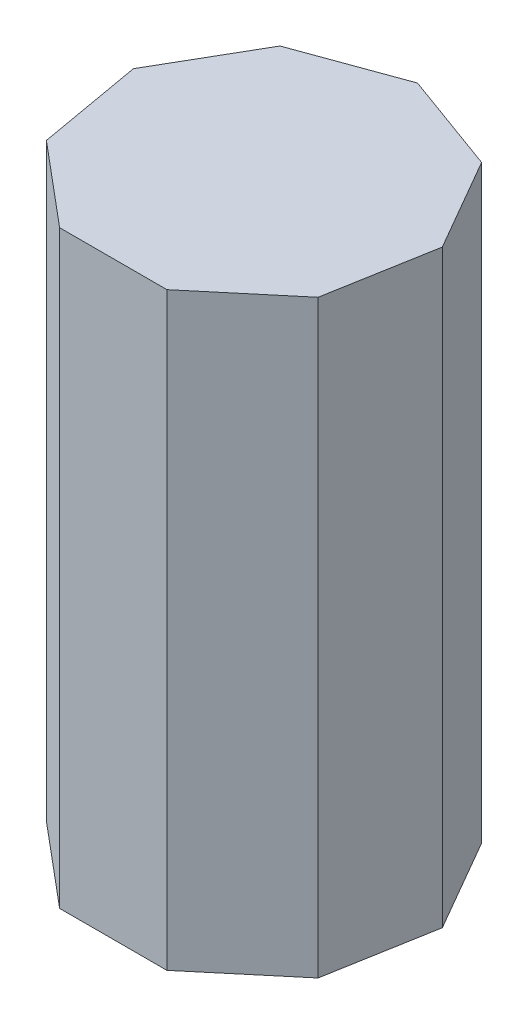
from build123d import *

# Parameters (mm, degrees)
EXTRUDE1_DEPTH = 20


with BuildPart() as part:
    # Sketch1 → Extrude1 (new body)
    with BuildSketch(Plane(origin=(0, 0, 0), x_dir=(1, 0, 0), z_dir=(0, 1, 0))):
        Polygon((5.240052605, 0.923962655), (3.420201433, 4.076037345), (0, 5.320888862), (-3.420201433, 4.076037345), (-5.240052605, 0.923962655), (-4.608024926, -2.660444431), (-1.819851171, -5), (1.819851171, -5), (4.608024926, -2.660444431), align=None)
    extrude(amount=EXTRUDE1_DEPTH)


solid = part.part
